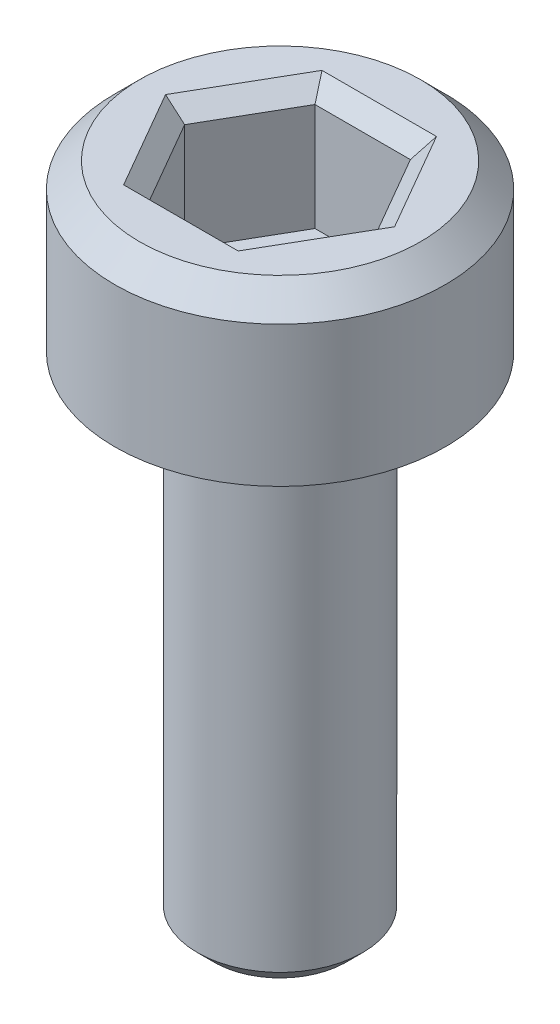
from build123d import *

# Parameters (mm, degrees)
SKETCH1_R           = 2
BOSS_EXTRUDE1_DEPTH = 2
CHAMFER1_SIZE       = 0.3
CUT_EXTRUDE1_DEPTH  = 1.5
CHAMFER2_SIZE       = 0.2
SKETCH3_R           = 1
BOSS_EXTRUDE2_DEPTH = 6
CHAMFER3_SIZE       = 0.2


with BuildPart() as part:
    # Sketch1 → Boss-Extrude1 (new body)
    with BuildSketch(Plane(origin=(0, 0, 0), x_dir=(1, 0, 0), z_dir=(0, 1, 0))):
        with Locations(Location((0, 0, 0), (0, 0, 270))):  # turned: the seam where the file's is
            Circle(SKETCH1_R)
    extrude(amount=BOSS_EXTRUDE1_DEPTH)

    # Chamfer1
    chamfer1_edges = [part.edges().sort_by_distance(p)[0] for p in [
        (0, 2, -2),
    ]]
    chamfer(chamfer1_edges, length=CHAMFER1_SIZE)

    # Sketch2 → Cut-Extrude1 (cut)
    with BuildSketch(Plane(origin=(0, 2, 0), x_dir=(1, 0, 0), z_dir=(0, 1, 0))):
        Polygon((1.154700538, 0), (0.577350269, 1), (-0.577350269, 1), (-1.154700538, 0), (-0.577350269, -1), (0.577350269, -1), align=None)
    extrude(amount=-CUT_EXTRUDE1_DEPTH, mode=Mode.SUBTRACT)

    # Chamfer2
    chamfer2_edges = [part.edges().sort_by_distance(p)[0] for p in [
        (0.866025404, 2, 0.5),
        (0.866025404, 2, -0.5),
        (0, 2, -1),
        (-0.866025404, 2, -0.5),
        (-0.866025404, 2, 0.5),
        (0, 2, 1),
    ]]
    chamfer(chamfer2_edges, length=CHAMFER2_SIZE)

    # Sketch3 → Boss-Extrude2 (add)
    with BuildSketch(Plane.XZ):
        with Locations(Location((0, 0, 0), (0, 0, 90))):  # turned: the seam where the file's is
            Circle(SKETCH3_R)
    extrude(amount=BOSS_EXTRUDE2_DEPTH)

    # Chamfer3
    chamfer3_edges = [part.edges().sort_by_distance(p)[0] for p in [
        (0, -6, -1),
    ]]
    chamfer(chamfer3_edges, length=CHAMFER3_SIZE)


solid = part.part
